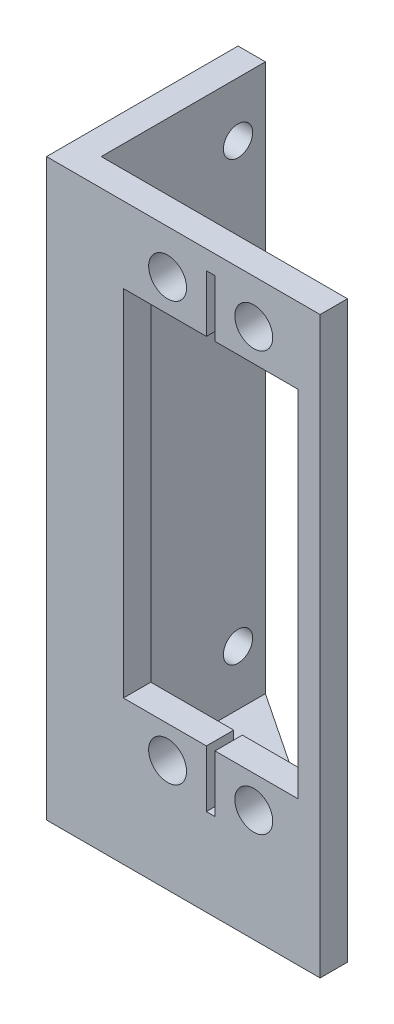
from build123d import *

# Parameters (mm, degrees)
SKETCH2_W           = 31.75
SKETCH2_H           = 63.5
BOSS_EXTRUDE1_DEPTH = 3.175
SKETCH3_R           = 2.200000045
CUT_EXTRUDE1_DEPTH  = 4.175
BOSS_EXTRUDE2_START = -3.175
SKETCH4_W           = 3.175
SKETCH4_H           = 63.5
BOSS_EXTRUDE2_DEPTH = 19.05
BOSS_EXTRUDE3_DEPTH = 3.175
SKETCH6_R           = 1.700000029
CUT_EXTRUDE2_DEPTH  = 4.175


with BuildPart() as part:
    # Sketch2 → Boss-Extrude1 (new body)
    with BuildSketch(Plane.XY):
        with Locations((15.875, 31.75)):
            Rectangle(SKETCH2_W, SKETCH2_H)
    extrude(amount=BOSS_EXTRUDE1_DEPTH)

    # Sketch3 → Cut-Extrude1 (cut, through all)
    with BuildSketch(Plane.XY.offset(3.175)):
        with Locations((14.049999967, 9.827000031)):
            Circle(SKETCH3_R)
        with Locations((24.050000033, 9.827000031)):
            Circle(SKETCH3_R)
        with Locations((14.049999967, 58.427000113)):
            Circle(SKETCH3_R)
        with Locations((24.050000033, 58.427000113)):
            Circle(SKETCH3_R)
        Polygon((8.923000061, 54.704000066), (18.55, 54.704000066), (18.55, 61.308000066), (19.55, 61.308000066), (19.55, 54.704000066), (29.176999939, 54.704000066), (29.176999939, 13.550000078), (19.55, 13.550000078), (19.55, 6.946000078), (18.55, 6.946000078), (18.55, 13.550000078), (8.923000061, 13.550000078), align=None)
    extrude(amount=-CUT_EXTRUDE1_DEPTH, mode=Mode.SUBTRACT)

    # Sketch4 → Boss-Extrude2 (add)
    with BuildSketch(Plane.XY.offset(3.175).offset(BOSS_EXTRUDE2_START)):
        with Locations((1.5875, 31.75)):
            Rectangle(SKETCH4_W, SKETCH4_H)
    extrude(amount=-BOSS_EXTRUDE2_DEPTH)

    # Sketch5 → Boss-Extrude3 (add)
    with BuildSketch(Plane.XZ):
        Polygon((0, 3.175), (31.75, 3.175), (31.75, 0), (3.175, -19.05), (0, -19.05), align=None)
    extrude(amount=BOSS_EXTRUDE3_DEPTH)

    # Sketch6 → Cut-Extrude2 (cut, through all)
    with BuildSketch(Plane(origin=(3.175, 0, 0), x_dir=(0, 0, -1), z_dir=(1, 0, 0))):
        with Locations((3.175, 57.15)):
            Circle(SKETCH6_R)
        with Locations((3.175, 6.35)):
            Circle(SKETCH6_R)
        with Locations((15.875, 57.15)):
            Circle(SKETCH6_R)
        with Locations((15.875, 6.35)):
            Circle(SKETCH6_R)
    extrude(amount=-CUT_EXTRUDE2_DEPTH, mode=Mode.SUBTRACT)


solid = part.part
